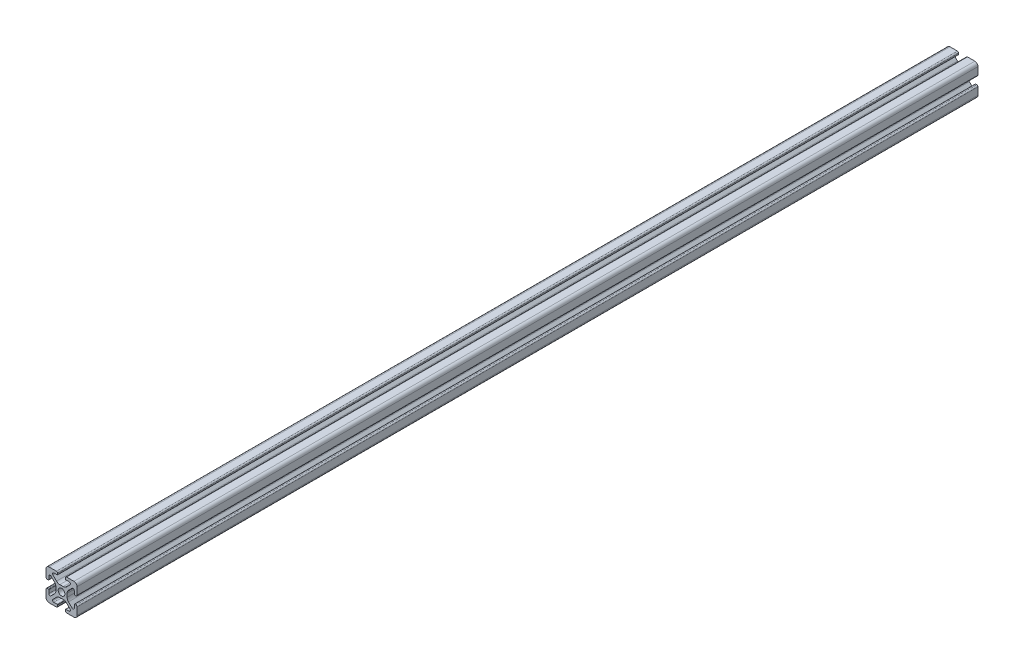
from build123d import *

# Parameters (mm, degrees)
SKETCH3_R           = 2.15
BOSS_EXTRUDE1_DEPTH = 580


with BuildPart() as part:
    # Sketch3 → Boss-Extrude1 (new body)
    with BuildSketch(Plane.XY):
        with BuildLine():
            Line((3.2874, 10), (8, 10))
            ThreePointArc((8, 10), (9.414213562, 9.414213562), (10, 8))
            Line((10, 8), (10, 3.2874))
            ThreePointArc((10, 3.2874), (9.76937588, 2.73062412), (9.2126, 2.5))
            Line((9.2126, 2.5), (8.5048, 2.5))
            ThreePointArc((8.5048, 2.5), (8.289273853, 2.589273853), (8.2, 2.8048))
            Line((8.2, 2.8048), (8.2, 4.9118))
            ThreePointArc((8.2, 4.9118), (7.682565253, 5.686195824), (6.769103096, 5.504496904))
            Line((6.769103096, 5.504496904), (4.478679656, 3.214073464))
            ThreePointArc((4.478679656, 3.214073464), (3.828361402, 2.240803418), (3.6, 1.092753121))
            Line((3.6, 1.092753121), (3.6, -1.092753121))
            ThreePointArc((3.6, -1.092753121), (3.828361402, -2.240803418), (4.478679656, -3.214073464))
            Line((4.478679656, -3.214073464), (6.769103096, -5.504496904))
            ThreePointArc((6.769103096, -5.504496904), (7.682565253, -5.686195824), (8.2, -4.9118))
            Line((8.2, -4.9118), (8.2, -2.8048))
            ThreePointArc((8.2, -2.8048), (8.289273853, -2.589273853), (8.5048, -2.5))
            Line((8.5048, -2.5), (9.2126, -2.5))
            ThreePointArc((9.2126, -2.5), (9.76937588, -2.73062412), (10, -3.2874))
            Line((10, -3.2874), (10, -8))
            ThreePointArc((10, -8), (9.414213562, -9.414213562), (8, -10))
            Line((8, -10), (3.2874, -10))
            ThreePointArc((3.2874, -10), (2.73062412, -9.76937588), (2.5, -9.2126))
            Line((2.5, -9.2126), (2.5, -8.5048))
            ThreePointArc((2.5, -8.5048), (2.589273853, -8.289273853), (2.8048, -8.2))
            Line((2.8048, -8.2), (4.9118, -8.2))
            ThreePointArc((4.9118, -8.2), (5.686195824, -7.682565253), (5.504496904, -6.769103096))
            Line((5.504496904, -6.769103096), (3.214073464, -4.478679656))
            ThreePointArc((3.214073464, -4.478679656), (2.240803418, -3.828361402), (1.092753121, -3.6))
            Line((1.092753121, -3.6), (-1.092753121, -3.6))
            ThreePointArc((-1.092753121, -3.6), (-2.240803418, -3.828361402), (-3.214073464, -4.478679656))
            Line((-3.214073464, -4.478679656), (-5.504496904, -6.769103096))
            ThreePointArc((-5.504496904, -6.769103096), (-5.686195824, -7.682565253), (-4.9118, -8.2))
            Line((-4.9118, -8.2), (-2.8048, -8.2))
            ThreePointArc((-2.8048, -8.2), (-2.589273853, -8.289273853), (-2.5, -8.5048))
            Line((-2.5, -8.5048), (-2.5, -9.2126))
            ThreePointArc((-2.5, -9.2126), (-2.73062412, -9.76937588), (-3.2874, -10))
            Line((-3.2874, -10), (-8, -10))
            ThreePointArc((-8, -10), (-9.414213562, -9.414213562), (-10, -8))
            Line((-10, -8), (-10, -3.2874))
            ThreePointArc((-10, -3.2874), (-9.76937588, -2.73062412), (-9.2126, -2.5))
            Line((-9.2126, -2.5), (-8.5048, -2.5))
            ThreePointArc((-8.5048, -2.5), (-8.289273853, -2.589273853), (-8.2, -2.8048))
            Line((-8.2, -2.8048), (-8.2, -4.9118))
            ThreePointArc((-8.2, -4.9118), (-7.682565253, -5.686195824), (-6.769103096, -5.504496904))
            Line((-6.769103096, -5.504496904), (-4.478679656, -3.214073464))
            ThreePointArc((-4.478679656, -3.214073464), (-3.828361402, -2.240803418), (-3.6, -1.092753121))
            Line((-3.6, -1.092753121), (-3.6, 1.092753121))
            ThreePointArc((-3.6, 1.092753121), (-3.828361402, 2.240803418), (-4.478679656, 3.214073464))
            Line((-4.478679656, 3.214073464), (-6.769103096, 5.504496904))
            ThreePointArc((-6.769103096, 5.504496904), (-7.682565253, 5.686195824), (-8.2, 4.9118))
            Line((-8.2, 4.9118), (-8.2, 2.8048))
            ThreePointArc((-8.2, 2.8048), (-8.289273853, 2.589273853), (-8.5048, 2.5))
            Line((-8.5048, 2.5), (-9.2126, 2.5))
            ThreePointArc((-9.2126, 2.5), (-9.76937588, 2.73062412), (-10, 3.2874))
            Line((-10, 3.2874), (-10, 8))
            ThreePointArc((-10, 8), (-9.414213562, 9.414213562), (-8, 10))
            Line((-8, 10), (-3.2874, 10))
            ThreePointArc((-3.2874, 10), (-2.73062412, 9.76937588), (-2.5, 9.2126))
            Line((-2.5, 9.2126), (-2.5, 8.5048))
            ThreePointArc((-2.5, 8.5048), (-2.589273853, 8.289273853), (-2.8048, 8.2))
            Line((-2.8048, 8.2), (-4.9118, 8.2))
            ThreePointArc((-4.9118, 8.2), (-5.686195824, 7.682565253), (-5.504496904, 6.769103096))
            Line((-5.504496904, 6.769103096), (-3.214073464, 4.478679656))
            ThreePointArc((-3.214073464, 4.478679656), (-2.240803418, 3.828361402), (-1.092753121, 3.6))
            Line((-1.092753121, 3.6), (1.092753121, 3.6))
            ThreePointArc((1.092753121, 3.6), (2.240803418, 3.828361402), (3.214073464, 4.478679656))
            Line((3.214073464, 4.478679656), (5.504496904, 6.769103096))
            ThreePointArc((5.504496904, 6.769103096), (5.686195824, 7.682565253), (4.9118, 8.2))
            Line((4.9118, 8.2), (2.8048, 8.2))
            ThreePointArc((2.8048, 8.2), (2.589273853, 8.289273853), (2.5, 8.5048))
            Line((2.5, 8.5048), (2.5, 9.2126))
            ThreePointArc((2.5, 9.2126), (2.73062412, 9.76937588), (3.2874, 10))
        make_face()
        Circle(SKETCH3_R, mode=Mode.SUBTRACT)
    extrude(amount=BOSS_EXTRUDE1_DEPTH)


solid = part.part
